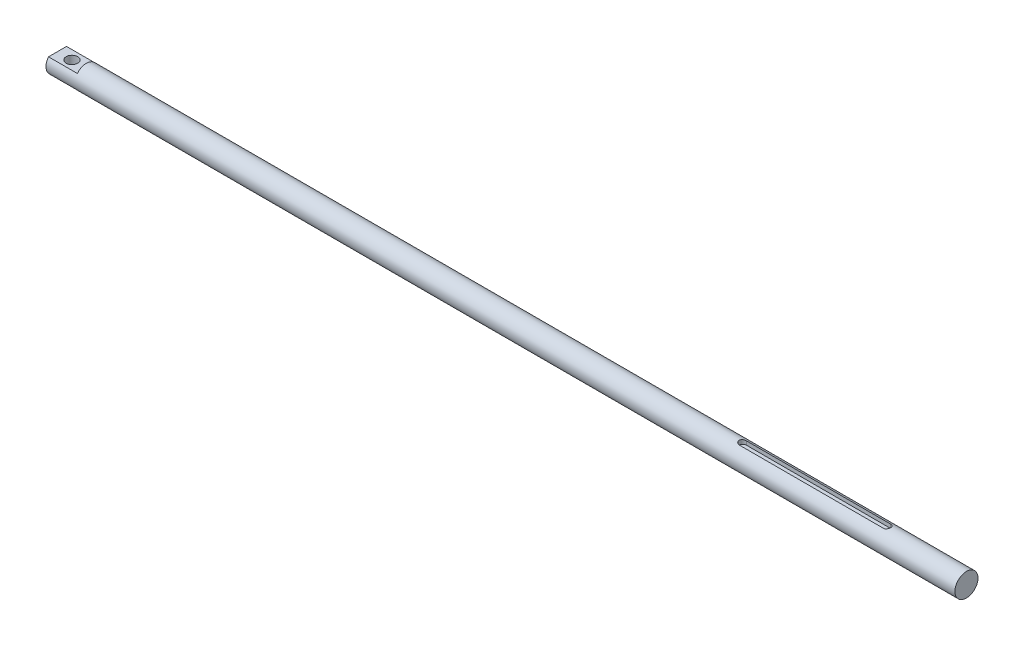
from build123d import *

# Parameters (mm, degrees)
SKETCH_1_R               = 8
EXTRUDE_1_DEPTH          = 630
SKETCH_2_R               = 4
CUT_EXTRUDE_1_DEPTH      = 9
CUT_EXTRUDE_1_DEPTH_BACK = 9
SKETCH_3_OUTSIDE_W       = 144.082
SKETCH_3_OUTSIDE_H       = 144.082
SKETCH_3_OUTSIDE_W_2     = 20
SKETCH_3_OUTSIDE_H_2     = 10
CUT_EXTRUDE_2_DEPTH      = 20
CUT_EXTRUDE_START        = 5
CUT_EXTRUDE_3_DEPTH      = 4


with BuildPart() as part:
    # 草图1 → 凸台-拉伸1 (new body)
    with BuildSketch(Plane(origin=(0, 0, 0), x_dir=(0, 0, -1), z_dir=(1, 0, 0))):
        Circle(SKETCH_1_R)
    extrude(amount=EXTRUDE_1_DEPTH)

    # 草图2 → 切除-拉伸1 (cut, two sides)
    with BuildSketch(Plane(origin=(0, 0, 0), x_dir=(1, 0, 0), z_dir=(0, 1, 0))) as cut_extrude_1_sk:
        with Locations((10, 0)):
            Circle(SKETCH_2_R)
    extrude(amount=CUT_EXTRUDE_1_DEPTH, mode=Mode.SUBTRACT)
    extrude(cut_extrude_1_sk.sketch, amount=-CUT_EXTRUDE_1_DEPTH_BACK, mode=Mode.SUBTRACT)

    # 草图3 outside → 切除-拉伸2 (cut)
    with BuildSketch(Plane.ZY):
        Rectangle(SKETCH_3_OUTSIDE_W, SKETCH_3_OUTSIDE_H)
        Rectangle(SKETCH_3_OUTSIDE_W_2, SKETCH_3_OUTSIDE_H_2, mode=Mode.SUBTRACT)
    extrude(amount=-CUT_EXTRUDE_2_DEPTH, mode=Mode.SUBTRACT)

    # 草图4 → 切除-拉伸3 (cut, through all)
    with BuildSketch(Plane(origin=(0, 0, 0), x_dir=(1, 0, 0), z_dir=(0, 1, 0)).offset(CUT_EXTRUDE_START)):
        with BuildLine():
            Line((475, 2.5), (575, 2.5))
            ThreePointArc((575, 2.5), (577.5, 0), (575, -2.5))
            Line((575, -2.5), (475, -2.5))
            ThreePointArc((475, -2.5), (472.5, 0), (475, 2.5))
        make_face()
    extrude(amount=CUT_EXTRUDE_3_DEPTH, mode=Mode.SUBTRACT)


solid = part.part
